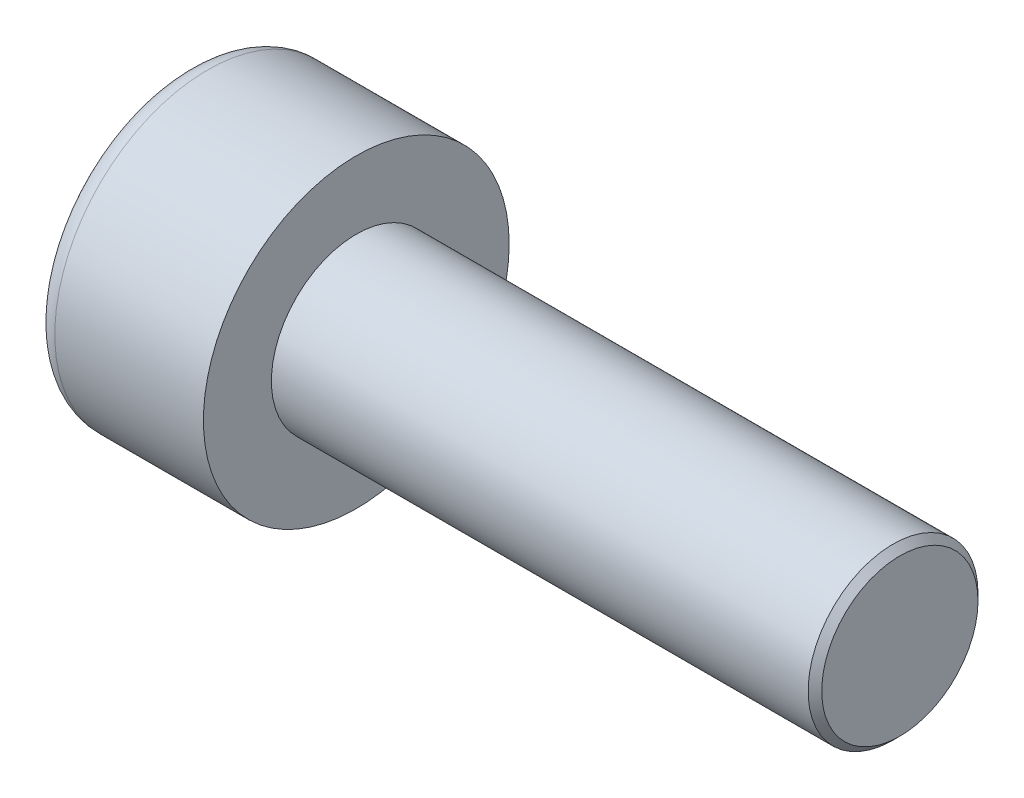
from build123d import *

# Parameters (mm, degrees)
SKETCH1_R           = 2.25
BASEHEAD_DEPTH      = 2.5
SKETCH2_R           = 1.25
BASEBODY_DEPTH      = 8
HEXAGONSOCKET_DEPTH = 1.1
TOPFILLET_R         = 0.3125
CHAMFER1_SIZE       = 0.1


with BuildPart() as part:
    # Sketch1 → BaseHead (new body)
    with BuildSketch(Plane(origin=(0, 0, 0), x_dir=(0, 0, -1), z_dir=(1, 0, 0))):
        Circle(SKETCH1_R)
    extrude(amount=BASEHEAD_DEPTH)

    # Sketch2 → BaseBody (add)
    with BuildSketch(Plane(origin=(2.5, 0, 0), x_dir=(0, 0, -1), z_dir=(1, 0, 0))):
        Circle(SKETCH2_R)
    extrude(amount=BASEBODY_DEPTH)

    # Sketch3 → HexagonSocket (cut)
    with BuildSketch(Plane(origin=(0, 0, 0), x_dir=(0, 0, -1), z_dir=(1, 0, 0))):
        Polygon((1.154700538, 0), (0.577350269, 1), (-0.577350269, 1), (-1.154700538, 0), (-0.577350269, -1), (0.577350269, -1), align=None)
    extrude(amount=HEXAGONSOCKET_DEPTH, mode=Mode.SUBTRACT)

    # Sketch4 → Cut-Revolve1 (revolve, cut)
    with BuildSketch(Plane(origin=(-4.19613823, 0.75, 0), x_dir=(-1, 0, 0), z_dir=(0, 0, 1))):
        Polygon((-5.29613823, 1.75), (-5.873488499, 0.75), (-5.29613823, 0.75), align=None)
    revolve(axis=Axis((0.838992387, 0, 0), (-1, 0, 0)), mode=Mode.SUBTRACT)

    # TopFillet
    topfillet_edges = [part.edges().sort_by_distance(p)[0] for p in [
        (0, 0, 2.25),
    ]]
    fillet(topfillet_edges, radius=TOPFILLET_R)

    # Chamfer1
    chamfer1_edges = [part.edges().sort_by_distance(p)[0] for p in [
        (10.5, 0, 1.25),
    ]]
    chamfer(chamfer1_edges, length=CHAMFER1_SIZE)


solid = part.part
